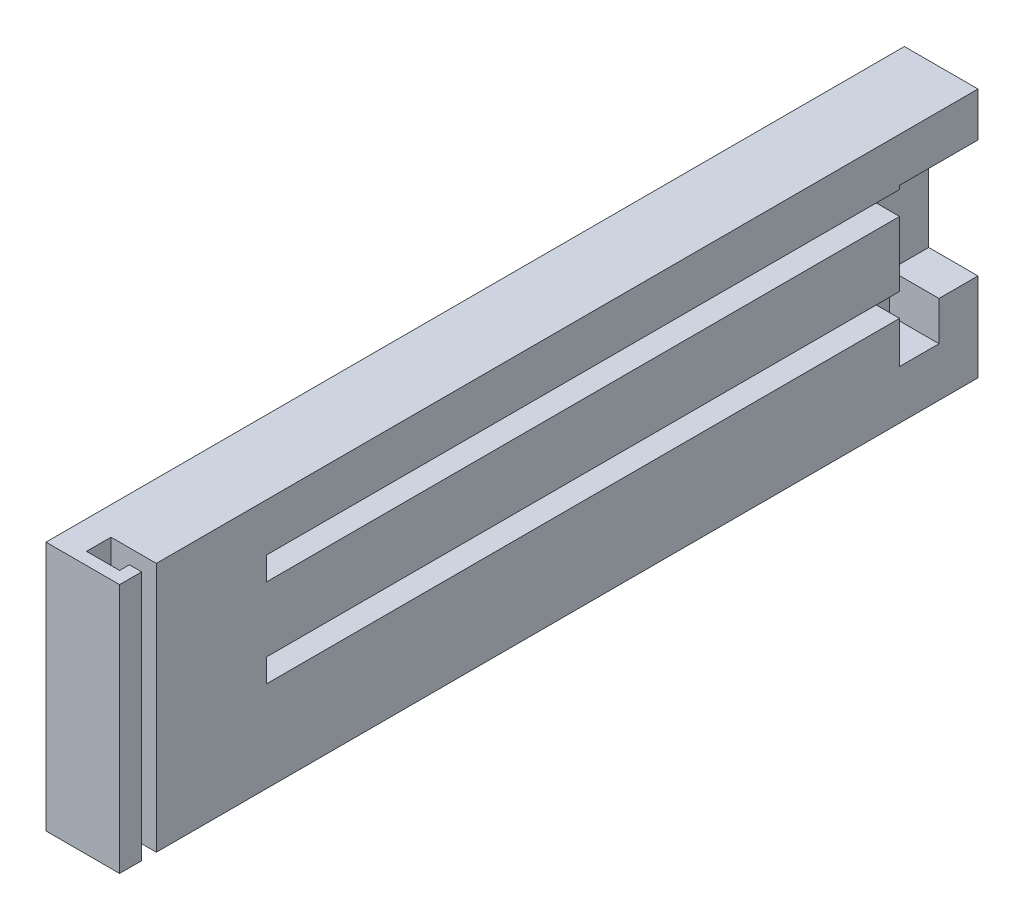
from build123d import *

# Parameters (mm, degrees)
SKETCH1_W           = 175
SKETCH1_H           = 51
BOSS_EXTRUDE1_DEPTH = 15
CUT_EXTRUDE3_DEPTH  = 52
SKETCH7_W           = 4.75
SKETCH7_H           = 4.75
CUT_EXTRUDE5_DEPTH  = 145
SKETCH8_W           = 10.05
SKETCH8_H           = 24
CUT_EXTRUDE6_DEPTH  = 16
SKETCH9_W           = 10.05
SKETCH9_H           = 8.05
CUT_EXTRUDE7_DEPTH  = 8


with BuildPart() as part:
    # Sketch1 → Boss-Extrude1 (new body)
    with BuildSketch(Plane(origin=(0, 0, 0), x_dir=(0, 0, -1), z_dir=(1, 0, 0))):
        with Locations((22.937921078, 5.057266603)):
            Rectangle(SKETCH1_W, SKETCH1_H)
    extrude(amount=BOSS_EXTRUDE1_DEPTH)

    # Sketch6 → Cut-Extrude3 (cut, through all)
    with BuildSketch(Plane(origin=(0, 30.557266603, 0), x_dir=(1, 0, 0), z_dir=(0, 1, 0))):
        Polygon((12.5, -60.062078922), (15, -60.062078922), (15, -57.062078922), (12.5, -57.062078922), (5.75, -57.062078922), (5.75, -62.062078922), (12.5, -62.062078922), align=None)
    extrude(amount=-CUT_EXTRUDE3_DEPTH, mode=Mode.SUBTRACT)

    # Sketch7 → Cut-Extrude5 (cut)
    with BuildSketch(Plane(origin=(0, 0, -110.437921078), x_dir=(-1, 0, 0), z_dir=(0, 0, -1))):
        with Locations((-12.625, 0.432266603)):
            Rectangle(SKETCH7_W, SKETCH7_H)
        with Locations((-12.625, 18.432266603)):
            Rectangle(SKETCH7_W, SKETCH7_H)
    extrude(amount=-CUT_EXTRUDE5_DEPTH, mode=Mode.SUBTRACT)

    # Sketch8 → Cut-Extrude6 (cut)
    with BuildSketch(Plane(origin=(0, 0, -110.437921078), x_dir=(-1, 0, 0), z_dir=(0, 0, -1))):
        with Locations((-9.975, 9.557266603)):
            Rectangle(SKETCH8_W, SKETCH8_H)
    extrude(amount=-CUT_EXTRUDE6_DEPTH, mode=Mode.SUBTRACT)

    # Sketch9 → Cut-Extrude7 (cut)
    with BuildSketch(Plane(origin=(0, -2.442733397, 0), x_dir=(1, 0, 0), z_dir=(0, 1, 0))):
        with Locations((9.975, 98.462921078)):
            Rectangle(SKETCH9_W, SKETCH9_H)
    extrude(amount=-CUT_EXTRUDE7_DEPTH, mode=Mode.SUBTRACT)


solid = part.part
